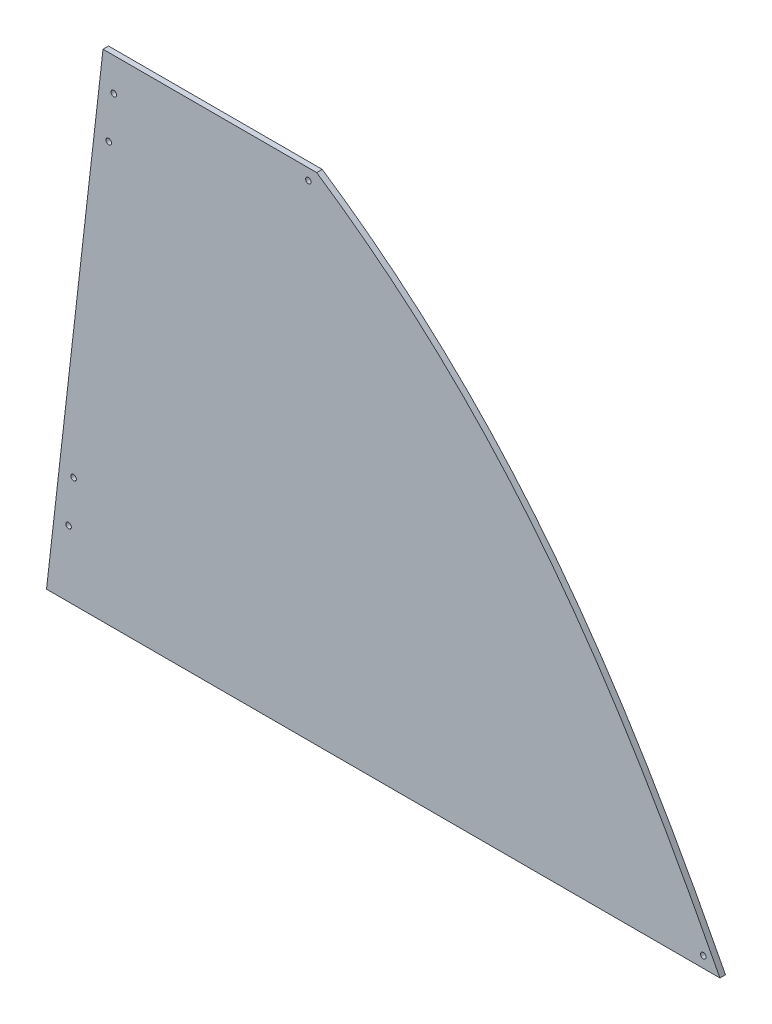
from build123d import *

# Parameters (mm, degrees)
BOSS_EXTRUDE1_DEPTH             = 6.35
BOSS_EXTRUDE2_DEPTH             = 6.35
F_1_4_0_25_DIAMETER_HOLE2_D     = 6.35
F_1_4_0_25_DIAMETER_HOLE3_D     = 6.35
F_1_4_0_25_DIAMETER_HOLE3_DEPTH = 6.35


with BuildPart() as part:
    # Sketch1 → Boss-Extrude1 (new body)
    with BuildSketch(Plane.XY):
        with BuildLine():
            Line((0, 0), (739.14, 0))
            add(Edge.make_bspline(
                [(277.420636668, 567.826315519), (496.859161811, 420.297110317), (620.758181585, 229.590161119), (739.14, 0)],
                knots=[0, 0, 0, 0, 1, 1, 1, 1], degree=3))
            Line((277.420636668, 567.826315519), (64.695636668, 567.826315519))
            Line((64.695636668, 567.826315519), (0, 0))
        make_face()
    extrude(amount=BOSS_EXTRUDE1_DEPTH)

    # Sketch5 → Boss-Extrude2 (add)
    with BuildSketch(Plane(origin=(0, 0, 0), x_dir=(-1, 0, 0), z_dir=(0, 0, -1))):
        Polygon((-64.695636668, 567.826315519), (-32.740222655, 567.826315519), (31.955414013, 0), (0, 0), align=None)
    extrude(amount=-BOSS_EXTRUDE2_DEPTH)

    # 1/4 (0.25) Diameter Hole2 (through all)
    with Locations(Plane.XY.offset(6.35)):
        with Locations((-6.712513837, 75.710175403), (-0.961790578, 126.183625671), (39.293272238, 479.49777755), (45.043995497, 529.971227818)):
            Hole(F_1_4_0_25_DIAMETER_HOLE2_D / 2)

    # 1/4 (0.25) Diameter Hole3
    with Locations(Plane.XY.offset(6.35)):
        with Locations((720.09, 12.7), (267.895636668, 555.126315519)):
            Hole(F_1_4_0_25_DIAMETER_HOLE3_D / 2, depth=F_1_4_0_25_DIAMETER_HOLE3_DEPTH)


solid = part.part
